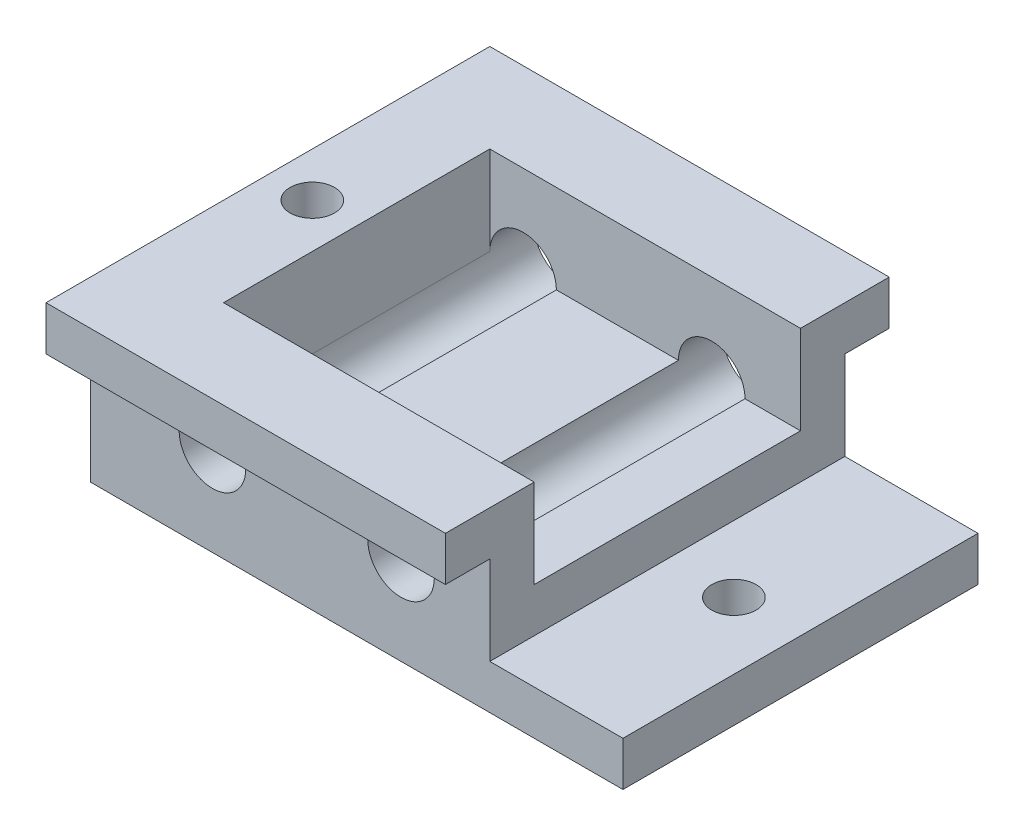
from build123d import *

# Parameters (mm, degrees)
SKETCH1_W               = 76.2
SKETCH1_H               = 50.8
BOSS_EXTRUDE1_DEPTH     = 6.35
SKETCH2_W               = 57.15
SKETCH2_H               = 50.8
BOSS_EXTRUDE2_DEPTH     = 6.35
BOSS_EXTRUDE3_DEPTH     = 6.35
BOSS_EXTRUDE4_DEPTH     = 6.35
SKETCH5_R               = 3.175
CUT_EXTRUDE1_DEPTH      = 26.4
SKETCH6_R               = 4.7625
CUT_EXTRUDE2_DEPTH      = 32.75
CUT_EXTRUDE2_DEPTH_BACK = 32.75


with BuildPart() as part:
    # Sketch1 → Boss-Extrude1 (new body)
    with BuildSketch(Plane(origin=(0, 0, 0), x_dir=(1, 0, 0), z_dir=(0, 1, 0))):
        Rectangle(SKETCH1_W, SKETCH1_H)
    extrude(amount=BOSS_EXTRUDE1_DEPTH)

    # Sketch2 → Boss-Extrude2 (add)
    with BuildSketch(Plane(origin=(0, 6.35, 0), x_dir=(1, 0, 0), z_dir=(0, 1, 0))):
        with Locations((-9.525, 0)):
            Rectangle(SKETCH2_W, SKETCH2_H)
    extrude(amount=BOSS_EXTRUDE2_DEPTH)

    # Sketch3 → Boss-Extrude3 (add)
    with BuildSketch(Plane(origin=(0, 12.7, 0), x_dir=(1, 0, 0), z_dir=(0, 1, 0))):
        Polygon((19.05, 25.4), (-38.1, 25.4), (-38.1, -25.4), (19.05, -25.4), (19.05, -19.05), (-25.4, -19.05), (-25.4, 19.05), (19.05, 19.05), align=None)
    extrude(amount=BOSS_EXTRUDE3_DEPTH)

    # Sketch4 → Boss-Extrude4 (add)
    with BuildSketch(Plane(origin=(0, 19.05, 0), x_dir=(1, 0, 0), z_dir=(0, 1, 0))):
        Polygon((19.05, 19.05), (19.05, 31.75), (-38.1, 31.75), (-38.1, -31.75), (19.05, -31.75), (19.05, -19.05), (-25.4, -19.05), (-25.4, 19.05), align=None)
    extrude(amount=BOSS_EXTRUDE4_DEPTH)

    # Sketch5 → Cut-Extrude1 (cut, through all)
    with BuildSketch(Plane(origin=(0, 0, 0), x_dir=(1, 0, 0), z_dir=(0, 1, 0))):
        with Locations((-31.75, 0)):
            Circle(SKETCH5_R)
        with Locations((28.575, 0)):
            Circle(SKETCH5_R)
    extrude(amount=CUT_EXTRUDE1_DEPTH, mode=Mode.SUBTRACT)

    # Sketch6 → Cut-Extrude2 (cut, two sides)
    with BuildSketch(Plane.XY) as cut_extrude2_sk:
        with Locations((-20.6375, 12.7)):
            Circle(SKETCH6_R)
        with Locations((6.35, 12.7)):
            Circle(SKETCH6_R)
    extrude(amount=CUT_EXTRUDE2_DEPTH, mode=Mode.SUBTRACT)
    extrude(cut_extrude2_sk.sketch, amount=-CUT_EXTRUDE2_DEPTH_BACK, mode=Mode.SUBTRACT)


solid = part.part
